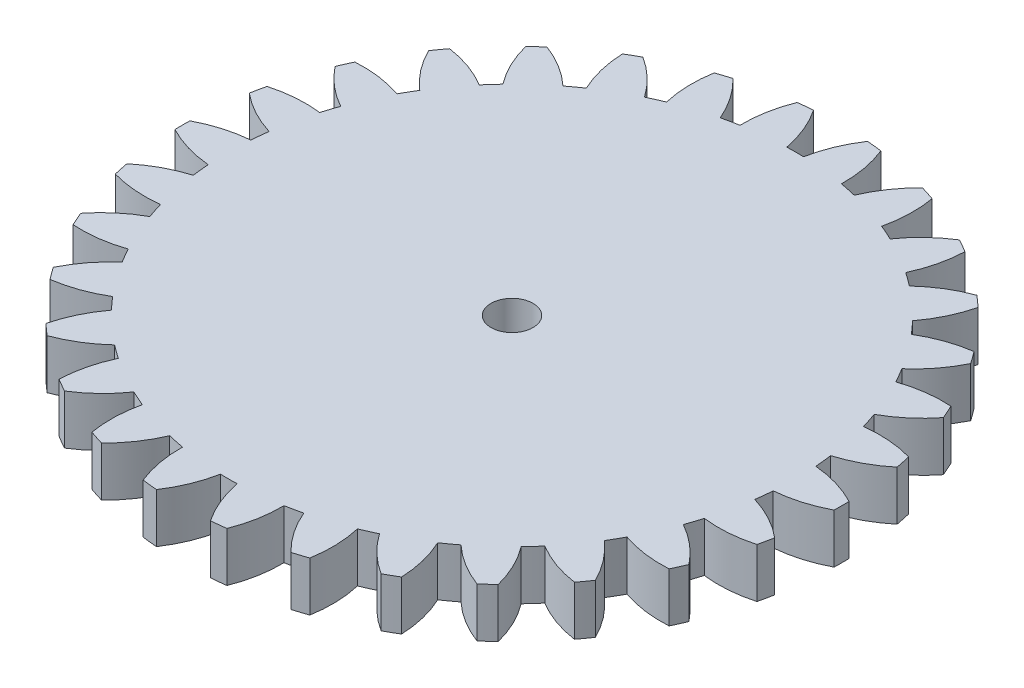
from build123d import *

# Parameters (mm, degrees)
SKETCH1_R           = 20
BOSS_EXTRUDE1_DEPTH = 3
CUT_EXTRUDE1_DEPTH  = 4
CIRPATTERN1_COUNT   = 30
SKETCH7_R           = 1.275
CUT_EXTRUDE6_DEPTH  = 4


with BuildPart() as part:
    # Sketch1 → Boss-Extrude1 (new body)
    with BuildSketch(Plane(origin=(0, 0, 0), x_dir=(1, 0, 0), z_dir=(0, 1, 0))):
        Circle(SKETCH1_R)
    extrude(amount=BOSS_EXTRUDE1_DEPTH)

    # Sketch2 → Cut-Extrude1 (cut, through all)
    with BuildSketch(Plane(origin=(0, 3, 0), x_dir=(1, 0, 0), z_dir=(0, 1, 0))):
        with BuildLine():
            ThreePointArc((-0.506578607, 17.180033014), (0, 17.1875), (0.506578607, 17.180033014))
            ThreePointArc((0.506578607, 17.180033014), (0.934108373, 18.613100259), (1.637465265, 19.932854976))
            ThreePointArc((1.637465265, 19.932854976), (0, 20), (-1.637465265, 19.932854976))
            ThreePointArc((-1.637465265, 19.932854976), (-0.934108373, 18.613100259), (-0.506578607, 17.180033014))
        make_face()
    cut_extrude1 = extrude(amount=-CUT_EXTRUDE1_DEPTH, mode=Mode.SUBTRACT)

    # CirPattern1: Cut-Extrude1 ×30 about axis
    cirpattern1_axis = Axis((0, 0, 0), (0, 1, 0))
    for i in range(1, CIRPATTERN1_COUNT):
        add(cut_extrude1.rotate(cirpattern1_axis, i * 360 / CIRPATTERN1_COUNT), mode=Mode.SUBTRACT)

    # Sketch7 → Cut-Extrude6 (cut, through all)
    with BuildSketch(Plane(origin=(0, 3, 0), x_dir=(1, 0, 0), z_dir=(0, 1, 0))):
        Circle(SKETCH7_R)
    extrude(amount=-CUT_EXTRUDE6_DEPTH, mode=Mode.SUBTRACT)


solid = part.part
